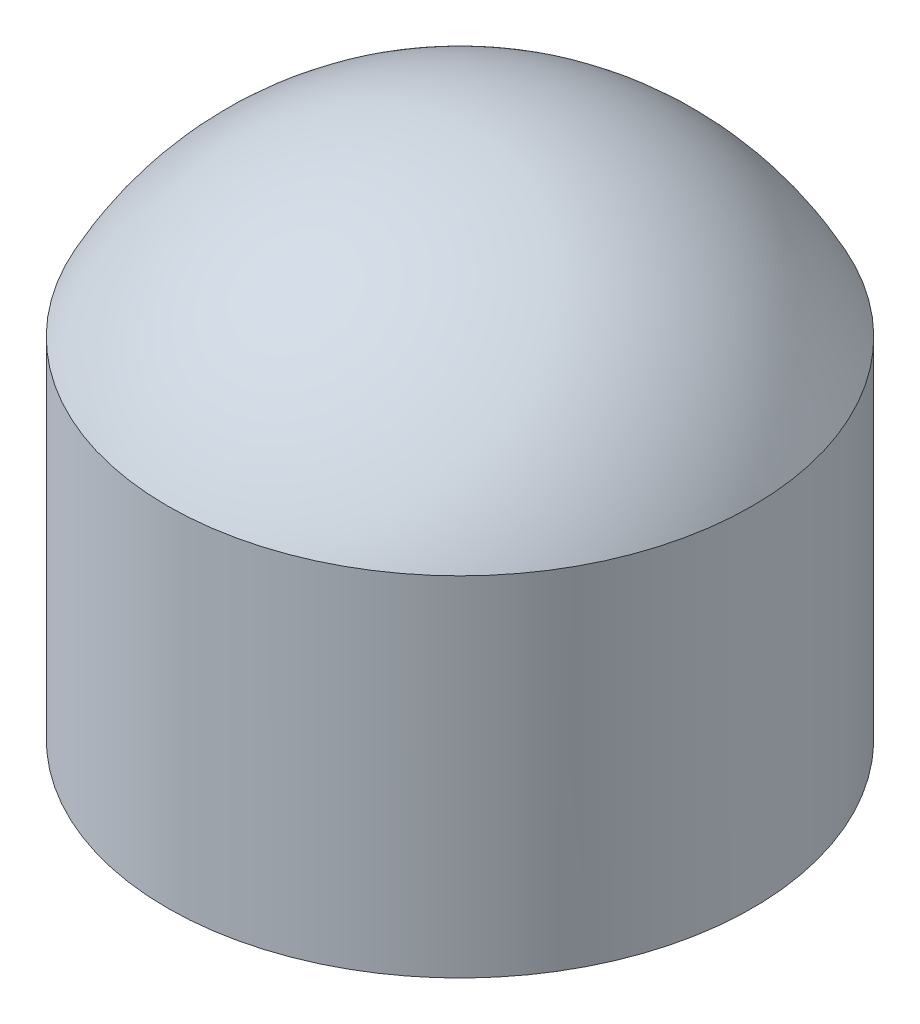
from build123d import *

# Parameters (mm, degrees)
SKETCH1_R           = 28.2067
BOSS_EXTRUDE1_DEPTH = 33.5788
SHELL1_T            = -4.064


with BuildPart() as part:
    # Sketch1 → Boss-Extrude1 (new body)
    with BuildSketch(Plane(origin=(0, 0, 0), x_dir=(1, 0, 0), z_dir=(0, 1, 0))):
        with Locations(Location((0, 0, 0), (0, 0, 270))):
            Circle(SKETCH1_R)
    extrude(amount=BOSS_EXTRUDE1_DEPTH)

    # Sketch2 → Revolve1 (revolve)
    with BuildSketch(Plane.XY, mode=Mode.PRIVATE) as revolve1_sk:
        with BuildLine():
            Line((0, 33.5788), (-28.2067, 33.5788))
            ThreePointArc((-28.2067, 33.5788), (-16.511981345, 46.121893901), (0, 50.753321445))
            Line((0, 50.753321445), (0, 33.5788))
        make_face()
    revolve(revolve1_sk.sketch.rotate(Axis((0, 50.753321445, 0), (0, -1, 0)), 180), axis=Axis((0, 50.753321445, 0), (0, -1, 0)))

    # Shell1
    shell1_openings = [part.faces().sort_by_distance(p)[0] for p in [
        (0, 0, 0),
    ]]
    offset(amount=SHELL1_T, openings=shell1_openings)


solid = part.part
